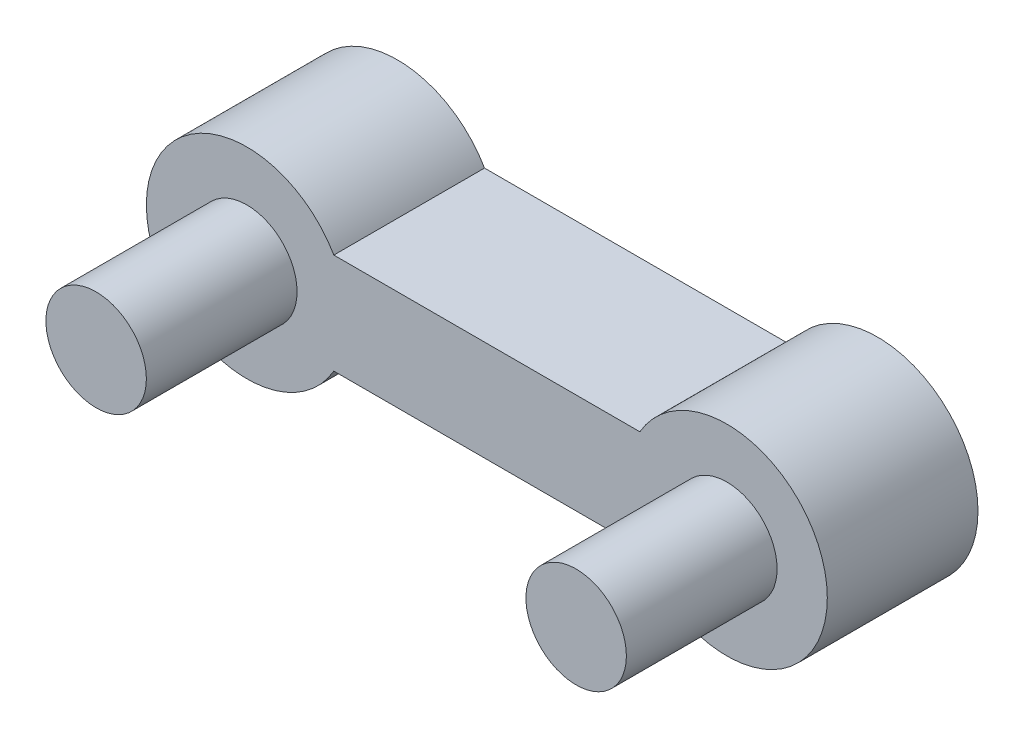
from build123d import *

# Parameters (mm, degrees)
BOSS_EXTRUDE1_DEPTH = 3
SKETCH3_R           = 1
BOSS_EXTRUDE2_DEPTH = 3


with BuildPart() as part:
    # Sketch2 → Boss-Extrude1 (new body)
    with BuildSketch(Plane.XY):
        with BuildLine():
            Line((-36.5050045, 13.800340042), (-30.412666324, 13.800340042))
            ThreePointArc((-30.412666324, 13.800340042), (-26.680615516, 12.800340042), (-30.412666324, 11.800340042))
            Line((-30.412666324, 11.800340042), (-36.5050045, 11.800340042))
            ThreePointArc((-36.5050045, 11.800340042), (-40.237055307, 12.800340042), (-36.5050045, 13.800340042))
        make_face()
    extrude(amount=BOSS_EXTRUDE1_DEPTH)

    # Sketch3 → Boss-Extrude2 (add)
    with BuildSketch(Plane.XY.offset(3)):
        with Locations((-28.680615516, 12.800340042)):
            Circle(SKETCH3_R)
        with Locations((-38.237055307, 12.800340042)):
            Circle(SKETCH3_R)
    extrude(amount=BOSS_EXTRUDE2_DEPTH)


solid = part.part
